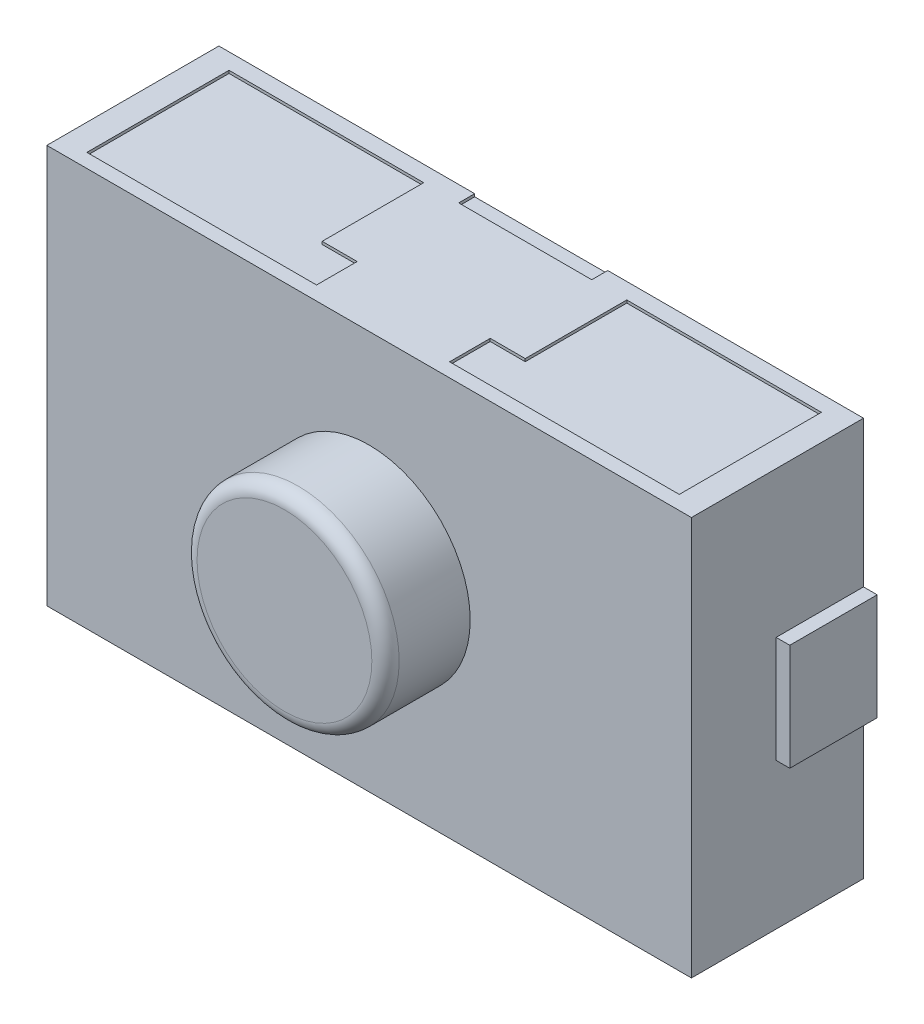
from build123d import *

# Parameters (mm, degrees)
SKETCH1_W           = 5.9944
SKETCH1_H           = 3.7084
BOSS_EXTRUDE1_DEPTH = 1.6002
SKETCH2_R           = 0.9398
BOSS_EXTRUDE2_DEPTH = 0.7874
SKETCH3_W           = 0.8128
SKETCH3_H           = 0.9906
BOSS_EXTRUDE3_DEPTH = 0.127
SKETCH4_W           = 0.8128
SKETCH4_H           = 0.9906
BOSS_EXTRUDE4_DEPTH = 0.127
SKETCH5_W           = 1.810256369
SKETCH5_H           = 1.321990986
SKETCH5_W_2         = 0.325593494
SKETCH5_H_2         = 0.377769853
SKETCH5_W_3         = 0.618627639
SKETCH5_H_3         = 0.148619884
CUT_EXTRUDE1_DEPTH  = 0.0254
SKETCH6_W           = 1.237255278
SKETCH6_H           = 0.148619884
CUT_EXTRUDE2_DEPTH  = 0.0254
FILLET1_R           = 0.127


with BuildPart() as part:
    # Sketch1 → Boss-Extrude1 (new body)
    with BuildSketch(Plane.XY):
        with Locations((2.9972, 1.8542)):
            Rectangle(SKETCH1_W, SKETCH1_H)
    extrude(amount=BOSS_EXTRUDE1_DEPTH)

    # Sketch2 → Boss-Extrude2 (add)
    with BuildSketch(Plane.XY.offset(1.6002)):
        with Locations((2.9972, 1.8542)):
            Circle(SKETCH2_R)
    extrude(amount=BOSS_EXTRUDE2_DEPTH)

    # Sketch3 → Boss-Extrude3 (add)
    with BuildSketch(Plane.ZY):
        with Locations((0.4064, 1.8542)):
            Rectangle(SKETCH3_W, SKETCH3_H)
    extrude(amount=BOSS_EXTRUDE3_DEPTH)

    # Sketch4 → Boss-Extrude4 (add)
    with BuildSketch(Plane(origin=(5.9944, 0, 0), x_dir=(0, 0, -1), z_dir=(1, 0, 0))):
        with Locations((-0.4064, 1.8542)):
            Rectangle(SKETCH4_W, SKETCH4_H)
    extrude(amount=BOSS_EXTRUDE4_DEPTH)

    # Sketch5 → Cut-Extrude1 (cut)
    with BuildSketch(Plane.XZ):
        with Locations((1.147850683, 0.809615377)):
            Rectangle(SKETCH5_W, SKETCH5_H)
        with Locations((2.215775614, 1.281725944)):
            Rectangle(SKETCH5_W_2, SKETCH5_H_2)
        with Locations((3.778624386, 1.281725944)):
            Rectangle(SKETCH5_W_2, SKETCH5_H_2)
        Polygon((5.751677502, 1.47061087), (3.941421133, 1.47061087), (3.941421133, 1.092841017), (3.941421133, 0.148619884), (5.751677502, 0.148619884), align=None)
        with Locations((2.687886181, 0.074309942)):
            Rectangle(SKETCH5_W_3, SKETCH5_H_3)
        with Locations((3.30651382, 0.074309942)):
            Rectangle(SKETCH5_W_3, SKETCH5_H_3)
    extrude(amount=-CUT_EXTRUDE1_DEPTH, mode=Mode.SUBTRACT)

    # Sketch6 → Cut-Extrude2 (cut)
    with BuildSketch(Plane(origin=(0, 3.7084, 0), x_dir=(1, 0, 0), z_dir=(0, 1, 0))):
        Polygon((3.941421133, -1.092841017), (3.615827639, -1.092841017), (3.615827639, -1.47061087), (5.751677502, -1.47061087), (5.751677502, -0.148619884), (3.941421133, -0.148619884), align=None)
        Polygon((2.052978867, -0.148619884), (0.242722498, -0.148619884), (0.242722498, -1.47061087), (2.378572361, -1.47061087), (2.378572361, -1.092841017), (2.052978867, -1.092841017), align=None)
        with Locations((2.9972, -0.074309942)):
            Rectangle(SKETCH6_W, SKETCH6_H)
    extrude(amount=-CUT_EXTRUDE2_DEPTH, mode=Mode.SUBTRACT)

    # Fillet1
    fillet1_edges = [part.edges().sort_by_distance(p)[0] for p in [
        (2.0574, 1.8542, 2.3876),
    ]]
    fillet(fillet1_edges, radius=FILLET1_R)


solid = part.part
